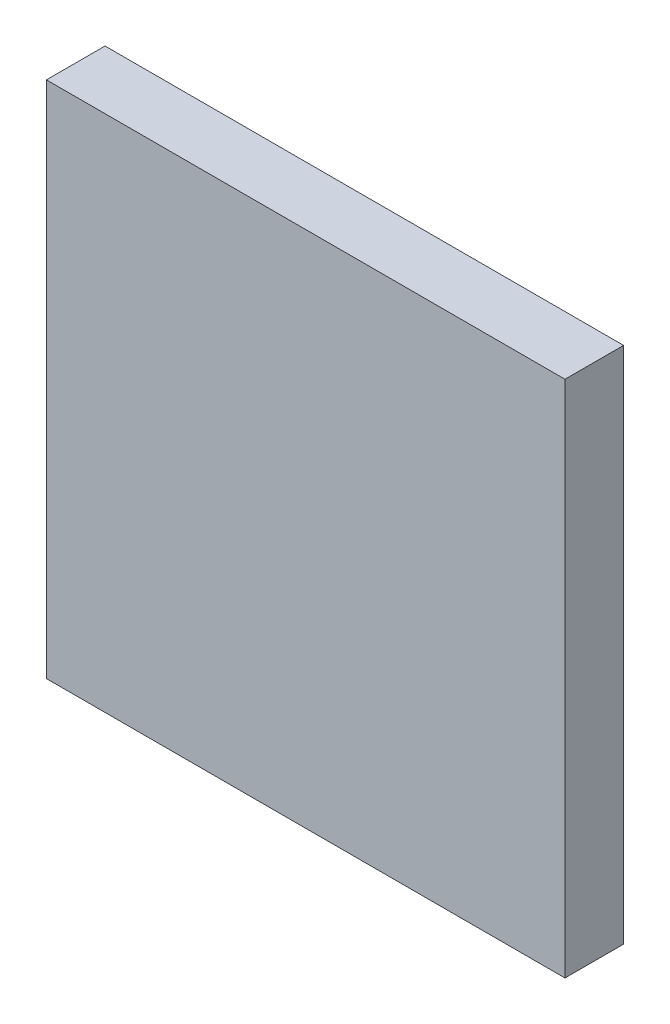
from build123d import *

# Parameters (mm, degrees)
SKETCH1_W      = 23
SKETCH1_H      = 23
EXTRUDE1_DEPTH = 2.6


with BuildPart() as part:
    # Sketch1 → Extrude1 (new body)
    with BuildSketch(Plane.XY):
        with Locations((11.5, -11.5)):
            Rectangle(SKETCH1_W, SKETCH1_H)
    extrude(amount=EXTRUDE1_DEPTH)


solid = part.part
